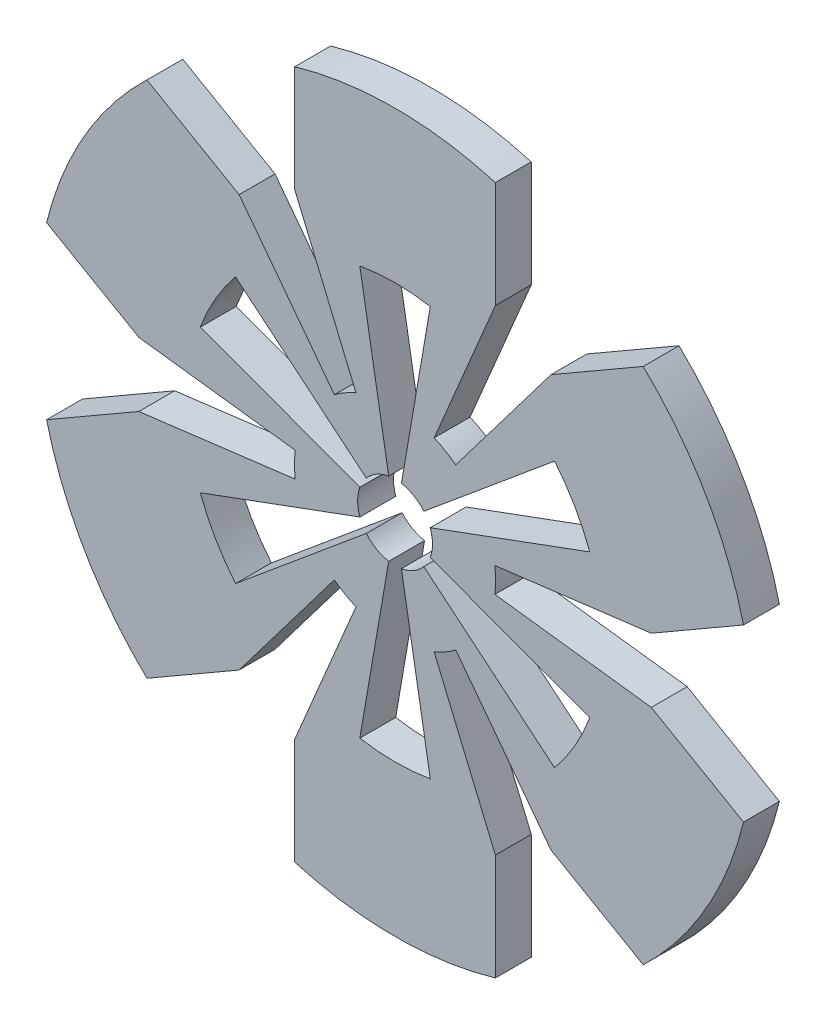
from build123d import *

# Parameters (mm, degrees)
EXTRUDE1_DEPTH     = 3.175
CUT_EXTRUDE1_DEPTH = 4.175


with BuildPart() as part:
    # Sketch1 → Extrude1 (new body)
    with BuildSketch(Plane.XY):
        with BuildLine():
            Line((22.679380466, 2.841623674), (30.838674439, 7.552394246))
            ThreePointArc((30.838674439, 7.552394246), (27.49630657, 15.875), (21.959902496, 22.93087836))
            Line((21.959902496, 22.93087836), (13.800608523, 18.220107788))
            ThreePointArc((13.800608523, 18.220107788), (11.428354249, 19.794490207), (8.878771943, 21.061731462))
            Line((8.878771943, 21.061731462), (8.878771943, 30.483272606))
            ThreePointArc((8.878771943, 30.483272606), (0, 31.75), (-8.878771943, 30.483272606))
            Line((-8.878771943, 30.483272606), (-8.878771943, 21.061731462))
            ThreePointArc((-8.878771943, 21.061731462), (-11.42835425, 19.794490207), (-13.800608523, 18.220107788))
            Line((-13.800608523, 18.220107788), (-21.959902496, 22.93087836))
            ThreePointArc((-21.959902496, 22.93087836), (-27.49630657, 15.875), (-30.838674439, 7.552394246))
            Line((-30.838674439, 7.552394246), (-22.679380466, 2.841623674))
            ThreePointArc((-22.679380466, 2.841623674), (-22.856708499, 0), (-22.679380466, -2.841623674))
            Line((-22.679380466, -2.841623674), (-30.838674439, -7.552394246))
            ThreePointArc((-30.838674439, -7.552394246), (-27.49630657, -15.875), (-21.959902496, -22.93087836))
            Line((-21.959902496, -22.93087836), (-13.800608523, -18.220107788))
            ThreePointArc((-13.800608523, -18.220107788), (-11.428354249, -19.794490207), (-8.878771943, -21.061731462))
            Line((-8.878771943, -21.061731462), (-8.878771943, -30.483272606))
            ThreePointArc((-8.878771943, -30.483272606), (0, -31.75), (8.878771943, -30.483272606))
            Line((8.878771943, -30.483272606), (8.878771943, -21.061731462))
            ThreePointArc((8.878771943, -21.061731462), (11.42835425, -19.794490207), (13.800608523, -18.220107788))
            Line((13.800608523, -18.220107788), (21.959902496, -22.93087836))
            ThreePointArc((21.959902496, -22.93087836), (27.49630657, -15.875), (30.838674439, -7.552394246))
            Line((30.838674439, -7.552394246), (22.679380466, -2.841623674))
            ThreePointArc((22.679380466, -2.841623674), (22.856708499, 0), (22.679380466, 2.841623674))
        make_face()
        with BuildLine():
            Line((5.081146111, 4.229650041), (2.54665271, 2.119885858))
            ThreePointArc((2.54665271, 2.119885858), (1.656755595, 2.869584813), (0.562548705, 3.265408865))
            Line((0.562548705, 3.265408865), (1.122411451, 6.515226654))
            Line((1.122411451, 6.515226654), (3.118088913, 18.09947505))
            ThreePointArc((3.118088913, 18.09947505), (1.4e-08, 18.366095814), (-3.118088886, 18.09947505))
            Line((-3.118088886, 18.09947505), (-1.122411315, 6.515226635))
            Line((-1.122411315, 6.515226635), (-0.562548631, 3.265408874))
            ThreePointArc((-0.562548631, 3.265408874), (-1.656755527, 2.869584841), (-2.546652654, 2.119885903))
            Line((-2.546652654, 2.119885903), (-5.081146055, 4.22965016))
            Line((-5.081146055, 4.22965016), (-14.115560718, 11.750081737))
            ThreePointArc((-14.115560718, 11.750081737), (-15.90550552, 9.183047919), (-17.233649617, 6.349393341))
            Line((-17.233649617, 6.349393341), (-6.203557422, 2.285576607))
            Line((-6.203557422, 2.285576607), (-3.109201328, 1.145523033))
            ThreePointArc((-3.109201328, 1.145523033), (-3.313511107, 5e-08), (-3.109201345, -1.145522936))
            Line((-3.109201345, -1.145522936), (-6.203557501, -2.285576481))
            Line((-6.203557501, -2.285576481), (-17.233649626, -6.3493933))
            ThreePointArc((-17.233649626, -6.3493933), (-15.905505528, -9.183047878), (-14.115560727, -11.750081696))
            Line((-14.115560727, -11.750081696), (-5.081146102, -4.229650015))
            Line((-5.081146102, -4.229650015), (-2.546652687, -2.119885812))
            ThreePointArc((-2.546652687, -2.119885812), (-1.656755574, -2.869584762), (-0.562548689, -3.265408812))
            Line((-0.562548689, -3.265408812), (-1.122411442, -6.515226628))
            Line((-1.122411442, -6.515226628), (-3.118088903, -18.099475024))
            ThreePointArc((-3.118088903, -18.099475024), (-4e-09, -18.366095785), (3.118088895, -18.099475024))
            Line((3.118088895, -18.099475024), (1.122411325, -6.515226609))
            Line((1.122411325, -6.515226609), (0.562548643, -3.265408824))
            ThreePointArc((0.562548643, -3.265408824), (1.656755537, -2.869584794), (2.546652665, -2.119885861))
            Line((2.546652665, -2.119885861), (5.081146064, -4.229650134))
            Line((5.081146064, -4.229650134), (14.115560728, -11.750081711))
            ThreePointArc((14.115560728, -11.750081711), (15.905505529, -9.183047893), (17.233649627, -6.349393315))
            Line((17.233649627, -6.349393315), (6.203557431, -2.285576582))
            Line((6.203557431, -2.285576582), (3.109201343, -1.145522994))
            ThreePointArc((3.109201343, -1.145522994), (3.313511126, -1.1e-08), (3.109201368, 1.145522978))
            Line((3.109201368, 1.145522978), (6.203557511, 2.285576507))
            Line((6.203557511, 2.285576507), (17.233649636, 6.349393326))
            ThreePointArc((17.233649636, 6.349393326), (15.905505541, 9.183047906), (14.115560736, 11.750081722))
            Line((14.115560736, 11.750081722), (5.081146111, 4.229650041))
        make_face(mode=Mode.SUBTRACT)
    extrude(amount=EXTRUDE1_DEPTH)

    # Sketch2 → Cut-Extrude1 (cut, through all)
    with BuildSketch(Plane.XY.offset(3.175)):
        with BuildLine():
            Line((8.878771943, 21.061731462), (3.458150609, 8.203233505))
            ThreePointArc((3.458150609, 8.203233505), (4.451175282, 7.709661742), (5.375133304, 7.09646303))
            Line((5.375133304, 7.09646303), (13.800608523, 18.220107788))
            ThreePointArc((13.800608523, 18.220107788), (11.428354249, 19.794490207), (8.878771943, 21.061731462))
        make_face()
        with BuildLine():
            Line((22.679380466, 2.841623674), (8.833283913, 1.106770475))
            ThreePointArc((8.833283913, 1.106770475), (8.902350564, 0), (8.833283913, -1.106770475))
            Line((8.833283913, -1.106770475), (22.679380466, -2.841623674))
            ThreePointArc((22.679380466, -2.841623674), (22.856708499, 0), (22.679380466, 2.841623674))
        make_face()
        with BuildLine():
            Line((13.800608523, -18.220107788), (5.375133304, -7.09646303))
            ThreePointArc((5.375133304, -7.09646303), (4.451175282, -7.709661742), (3.458150609, -8.203233505))
            Line((3.458150609, -8.203233505), (8.878771943, -21.061731462))
            ThreePointArc((8.878771943, -21.061731462), (11.42835425, -19.794490207), (13.800608523, -18.220107788))
        make_face()
        with BuildLine():
            Line((-8.878771943, -21.061731462), (-3.458150609, -8.203233505))
            ThreePointArc((-3.458150609, -8.203233505), (-4.451175282, -7.709661742), (-5.375133304, -7.09646303))
            Line((-5.375133304, -7.09646303), (-13.800608523, -18.220107788))
            ThreePointArc((-13.800608523, -18.220107788), (-11.428354249, -19.794490207), (-8.878771943, -21.061731462))
        make_face()
        with BuildLine():
            Line((-22.679380466, -2.841623674), (-8.833283913, -1.106770475))
            ThreePointArc((-8.833283913, -1.106770475), (-8.902350564, 0), (-8.833283913, 1.106770475))
            Line((-8.833283913, 1.106770475), (-22.679380466, 2.841623674))
            ThreePointArc((-22.679380466, 2.841623674), (-22.856708499, 0), (-22.679380466, -2.841623674))
        make_face()
        with BuildLine():
            Line((-13.800608523, 18.220107788), (-5.375133304, 7.09646303))
            ThreePointArc((-5.375133304, 7.09646303), (-4.451175282, 7.709661742), (-3.458150609, 8.203233505))
            Line((-3.458150609, 8.203233505), (-8.878771943, 21.061731462))
            ThreePointArc((-8.878771943, 21.061731462), (-11.42835425, 19.794490207), (-13.800608523, 18.220107788))
        make_face()
    extrude(amount=-CUT_EXTRUDE1_DEPTH, mode=Mode.SUBTRACT)


solid = part.part
